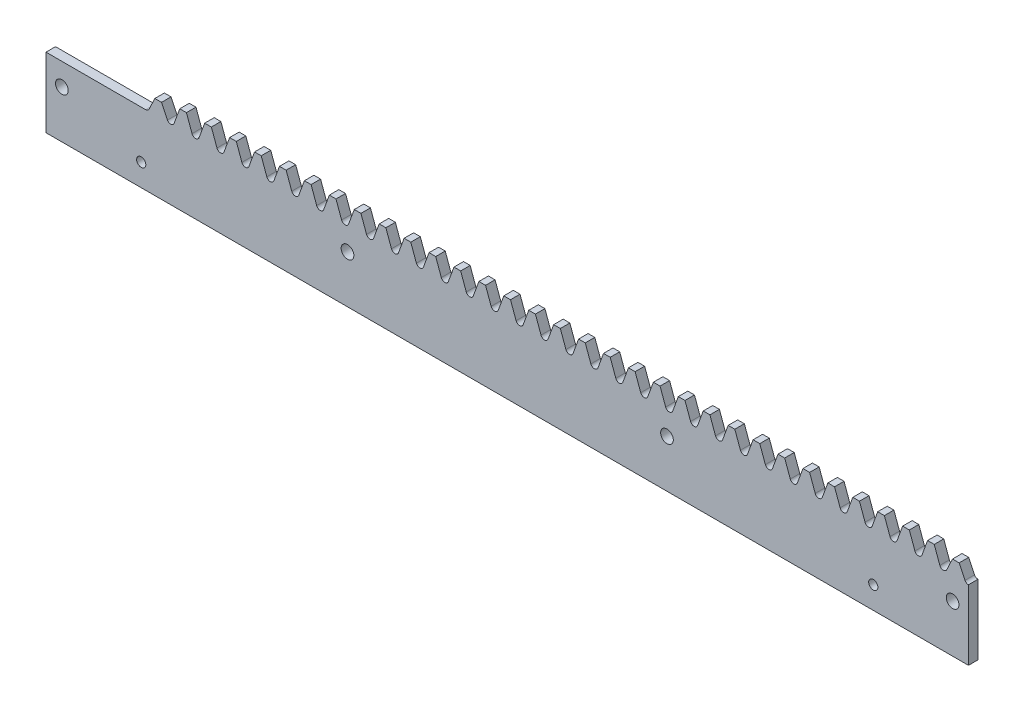
from build123d import *

# Parameters (mm, degrees)
ESQUISSE1_R             = 2
EXTRUSION1_DEPTH        = 3
ESQUISSE4_R             = 1.45
ENL_V_MAT_EXTRU_2_DEPTH = 4


with BuildPart() as part:
    # Esquisse1 → Extrusion1 (new body)
    with BuildSketch(Plane.XY):
        with BuildLine():
            Line((-11.780972452, 22), (19.634954087, 22))
            ThreePointArc((19.634954087, 22), (20.207764851, 22.148388876), (20.636482657, 22.556227657))
            Line((20.636482657, 22.556227657), (22.508375082, 26.5))
            Line((22.508375082, 26.5), (24.615514728, 26.5))
            Line((24.615514728, 26.5), (26.487407153, 22.556227657))
            ThreePointArc((26.487407153, 22.556227657), (26.916124959, 22.148388876), (27.488935722, 22))
            ThreePointArc((27.488935722, 22), (28.165627746, 22.213360175), (28.597563031, 22.776269199))
            Line((28.597563031, 22.776269199), (30.362356717, 27.625))
            Line((30.362356717, 27.625), (32.469496363, 27.625))
            Line((32.469496363, 27.625), (34.234290049, 22.776269199))
            ThreePointArc((34.234290049, 22.776269199), (34.666225334, 22.213360175), (35.342917357, 22))
            ThreePointArc((35.342917357, 22), (36.019609381, 22.213360175), (36.451544666, 22.776269199))
            Line((36.451544666, 22.776269199), (38.216338352, 27.625))
            Line((38.216338352, 27.625), (40.323477998, 27.625))
            Line((40.323477998, 27.625), (42.088271684, 22.776269199))
            ThreePointArc((42.088271684, 22.776269199), (42.520206969, 22.213360175), (43.196898992, 22))
            ThreePointArc((43.196898992, 22), (43.873591016, 22.213360175), (44.305526301, 22.776269199))
            Line((44.305526301, 22.776269199), (46.070319987, 27.625))
            Line((46.070319987, 27.625), (48.177459633, 27.625))
            Line((48.177459633, 27.625), (49.942253319, 22.776269199))
            ThreePointArc((49.942253319, 22.776269199), (50.374188604, 22.213360175), (51.050880627, 22))
            ThreePointArc((51.050880627, 22), (51.727572651, 22.213360175), (52.159507936, 22.776269199))
            Line((52.159507936, 22.776269199), (53.924301622, 27.625))
            Line((53.924301622, 27.625), (56.031441268, 27.625))
            Line((56.031441268, 27.625), (57.796234954, 22.776269199))
            ThreePointArc((57.796234954, 22.776269199), (58.228170239, 22.213360175), (58.904862262, 22))
            ThreePointArc((58.904862262, 22), (59.581554286, 22.213360175), (60.013489571, 22.776269199))
            Line((60.013489571, 22.776269199), (61.778283257, 27.625))
            Line((61.778283257, 27.625), (63.885422903, 27.625))
            Line((63.885422903, 27.625), (65.650216589, 22.776269199))
            ThreePointArc((65.650216589, 22.776269199), (66.082151874, 22.213360175), (66.758843897, 22))
            ThreePointArc((66.758843897, 22), (67.435535921, 22.213360175), (67.867471206, 22.776269199))
            Line((67.867471206, 22.776269199), (69.632264892, 27.625))
            Line((69.632264892, 27.625), (71.739404538, 27.625))
            Line((71.739404538, 27.625), (73.504198224, 22.776269199))
            ThreePointArc((73.504198224, 22.776269199), (73.936133509, 22.213360175), (74.612825532, 22))
            ThreePointArc((74.612825532, 22), (75.289517556, 22.213360175), (75.721452841, 22.776269199))
            Line((75.721452841, 22.776269199), (77.486246527, 27.625))
            Line((77.486246527, 27.625), (79.593386173, 27.625))
            Line((79.593386173, 27.625), (81.358179859, 22.776269199))
            ThreePointArc((81.358179859, 22.776269199), (81.790115144, 22.213360175), (82.466807167, 22))
            ThreePointArc((82.466807167, 22), (83.143499191, 22.213360175), (83.575434476, 22.776269199))
            Line((83.575434476, 22.776269199), (85.340228162, 27.625))
            Line((85.340228162, 27.625), (87.447367808, 27.625))
            Line((87.447367808, 27.625), (89.212161494, 22.776269199))
            ThreePointArc((89.212161494, 22.776269199), (89.644096779, 22.213360175), (90.320788802, 22))
            ThreePointArc((90.320788802, 22), (90.997480826, 22.213360175), (91.429416111, 22.776269199))
            Line((91.429416111, 22.776269199), (93.194209797, 27.625))
            Line((93.194209797, 27.625), (95.301349443, 27.625))
            Line((95.301349443, 27.625), (97.066143129, 22.776269199))
            ThreePointArc((97.066143129, 22.776269199), (97.498078414, 22.213360175), (98.174770437, 22))
            ThreePointArc((98.174770437, 22), (98.851462461, 22.213360175), (99.283397746, 22.776269199))
            Line((99.283397746, 22.776269199), (101.048191432, 27.625))
            Line((101.048191432, 27.625), (103.155331078, 27.625))
            Line((103.155331078, 27.625), (104.920124764, 22.776269199))
            ThreePointArc((104.920124764, 22.776269199), (105.352060049, 22.213360175), (106.028752072, 22))
            ThreePointArc((106.028752072, 22), (106.705444096, 22.213360175), (107.137379381, 22.776269199))
            Line((107.137379381, 22.776269199), (108.902173067, 27.625))
            Line((108.902173067, 27.625), (111.009312713, 27.625))
            Line((111.009312713, 27.625), (112.774106399, 22.776269199))
            ThreePointArc((112.774106399, 22.776269199), (113.206041684, 22.213360175), (113.882733707, 22))
            ThreePointArc((113.882733707, 22), (114.559425731, 22.213360175), (114.991361016, 22.776269199))
            Line((114.991361016, 22.776269199), (116.756154702, 27.625))
            Line((116.756154702, 27.625), (118.863294348, 27.625))
            Line((118.863294348, 27.625), (120.628088034, 22.776269199))
            ThreePointArc((120.628088034, 22.776269199), (121.060023319, 22.213360175), (121.736715342, 22))
            ThreePointArc((121.736715342, 22), (122.413407366, 22.213360175), (122.845342651, 22.776269199))
            Line((122.845342651, 22.776269199), (124.610136337, 27.625))
            Line((124.610136337, 27.625), (126.717275983, 27.625))
            Line((126.717275983, 27.625), (128.482069669, 22.776269199))
            ThreePointArc((128.482069669, 22.776269199), (128.914004954, 22.213360175), (129.590696977, 22))
            ThreePointArc((129.590696977, 22), (130.267389001, 22.213360175), (130.699324286, 22.776269199))
            Line((130.699324286, 22.776269199), (132.464117972, 27.625))
            Line((132.464117972, 27.625), (134.571257618, 27.625))
            Line((134.571257618, 27.625), (136.336051304, 22.776269199))
            ThreePointArc((136.336051304, 22.776269199), (136.767986589, 22.213360175), (137.444678612, 22))
            ThreePointArc((137.444678612, 22), (138.121370636, 22.213360175), (138.553305921, 22.776269199))
            Line((138.553305921, 22.776269199), (140.318099607, 27.625))
            Line((140.318099607, 27.625), (142.425239253, 27.625))
            Line((142.425239253, 27.625), (144.190032939, 22.776269199))
            ThreePointArc((144.190032939, 22.776269199), (144.621968224, 22.213360175), (145.298660247, 22))
            ThreePointArc((145.298660247, 22), (145.975352271, 22.213360175), (146.407287556, 22.776269199))
            Line((146.407287556, 22.776269199), (148.172081242, 27.625))
            Line((148.172081242, 27.625), (150.279220888, 27.625))
            Line((150.279220888, 27.625), (152.044014574, 22.776269199))
            ThreePointArc((152.044014574, 22.776269199), (152.475949859, 22.213360175), (153.152641882, 22))
            ThreePointArc((153.152641882, 22), (153.829333906, 22.213360175), (154.261269191, 22.776269199))
            Line((154.261269191, 22.776269199), (156.026062877, 27.625))
            Line((156.026062877, 27.625), (158.133202523, 27.625))
            Line((158.133202523, 27.625), (159.897996209, 22.776269199))
            ThreePointArc((159.897996209, 22.776269199), (160.329931494, 22.213360175), (161.006623517, 22))
            ThreePointArc((161.006623517, 22), (161.683315541, 22.213360175), (162.115250826, 22.776269199))
            Line((162.115250826, 22.776269199), (163.880044512, 27.625))
            Line((163.880044512, 27.625), (165.987184158, 27.625))
            Line((165.987184158, 27.625), (167.751977844, 22.776269199))
            ThreePointArc((167.751977844, 22.776269199), (168.183913129, 22.213360175), (168.860605152, 22))
            ThreePointArc((168.860605152, 22), (169.537297176, 22.213360175), (169.969232461, 22.776269199))
            Line((169.969232461, 22.776269199), (171.734026147, 27.625))
            Line((171.734026147, 27.625), (173.841165793, 27.625))
            Line((173.841165793, 27.625), (175.605959479, 22.776269199))
            ThreePointArc((175.605959479, 22.776269199), (176.037894764, 22.213360175), (176.714586787, 22))
            ThreePointArc((176.714586787, 22), (177.391278811, 22.213360175), (177.823214096, 22.776269199))
            Line((177.823214096, 22.776269199), (179.588007782, 27.625))
            Line((179.588007782, 27.625), (181.695147428, 27.625))
            Line((181.695147428, 27.625), (183.459941114, 22.776269199))
            ThreePointArc((183.459941114, 22.776269199), (183.891876399, 22.213360175), (184.568568422, 22))
            ThreePointArc((184.568568422, 22), (185.245260446, 22.213360175), (185.677195731, 22.776269199))
            Line((185.677195731, 22.776269199), (187.441989417, 27.625))
            Line((187.441989417, 27.625), (189.549129063, 27.625))
            Line((189.549129063, 27.625), (191.313922749, 22.776269199))
            ThreePointArc((191.313922749, 22.776269199), (191.745858034, 22.213360175), (192.422550057, 22))
            ThreePointArc((192.422550057, 22), (193.099242081, 22.213360175), (193.531177366, 22.776269199))
            Line((193.531177366, 22.776269199), (195.295971052, 27.625))
            Line((195.295971052, 27.625), (197.403110698, 27.625))
            Line((197.403110698, 27.625), (199.167904384, 22.776269199))
            ThreePointArc((199.167904384, 22.776269199), (199.599839669, 22.213360175), (200.276531692, 22))
            ThreePointArc((200.276531692, 22), (200.953223716, 22.213360175), (201.385159001, 22.776269199))
            Line((201.385159001, 22.776269199), (203.149952687, 27.625))
            Line((203.149952687, 27.625), (205.257092333, 27.625))
            Line((205.257092333, 27.625), (207.021886019, 22.776269199))
            ThreePointArc((207.021886019, 22.776269199), (207.453821304, 22.213360175), (208.130513327, 22))
            ThreePointArc((208.130513327, 22), (208.807205351, 22.213360175), (209.239140636, 22.776269199))
            Line((209.239140636, 22.776269199), (211.003934322, 27.625))
            Line((211.003934322, 27.625), (213.111073968, 27.625))
            Line((213.111073968, 27.625), (214.875867654, 22.776269199))
            ThreePointArc((214.875867654, 22.776269199), (215.307802939, 22.213360175), (215.984494962, 22))
            ThreePointArc((215.984494962, 22), (216.661186986, 22.213360175), (217.093122271, 22.776269199))
            Line((217.093122271, 22.776269199), (218.857915957, 27.625))
            Line((218.857915957, 27.625), (220.965055603, 27.625))
            Line((220.965055603, 27.625), (222.729849289, 22.776269199))
            ThreePointArc((222.729849289, 22.776269199), (223.161784574, 22.213360175), (223.838476597, 22))
            ThreePointArc((223.838476597, 22), (224.515168621, 22.213360175), (224.947103906, 22.776269199))
            Line((224.947103906, 22.776269199), (226.711897592, 27.625))
            Line((226.711897592, 27.625), (228.819037238, 27.625))
            Line((228.819037238, 27.625), (230.583830924, 22.776269199))
            ThreePointArc((230.583830924, 22.776269199), (231.015766209, 22.213360175), (231.692458232, 22))
            ThreePointArc((231.692458232, 22), (232.369150256, 22.213360175), (232.801085541, 22.776269199))
            Line((232.801085541, 22.776269199), (234.565879227, 27.625))
            Line((234.565879227, 27.625), (236.673018873, 27.625))
            Line((236.673018873, 27.625), (238.437812559, 22.776269199))
            ThreePointArc((238.437812559, 22.776269199), (238.869747844, 22.213360175), (239.546439867, 22))
            ThreePointArc((239.546439867, 22), (240.223131891, 22.213360175), (240.655067176, 22.776269199))
            Line((240.655067176, 22.776269199), (242.419860862, 27.625))
            Line((242.419860862, 27.625), (244.527000508, 27.625))
            Line((244.527000508, 27.625), (246.291794194, 22.776269199))
            ThreePointArc((246.291794194, 22.776269199), (246.723729479, 22.213360175), (247.400421502, 22))
            ThreePointArc((247.400421502, 22), (248.077113526, 22.213360175), (248.509048811, 22.776269199))
            Line((248.509048811, 22.776269199), (250.273842497, 27.625))
            Line((250.273842497, 27.625), (252.380982143, 27.625))
            Line((252.380982143, 27.625), (254.145775829, 22.776269199))
            ThreePointArc((254.145775829, 22.776269199), (254.577711114, 22.213360175), (255.254403137, 22))
            ThreePointArc((255.254403137, 22), (255.931095161, 22.213360175), (256.363030446, 22.776269199))
            Line((256.363030446, 22.776269199), (258.127824132, 27.625))
            Line((258.127824132, 27.625), (260.234963778, 27.625))
            Line((260.234963778, 27.625), (261.999757464, 22.776269199))
            ThreePointArc((261.999757464, 22.776269199), (262.431692749, 22.213360175), (263.108384772, 22))
            ThreePointArc((263.108384772, 22), (263.785076796, 22.213360175), (264.217012081, 22.776269199))
            Line((264.217012081, 22.776269199), (265.981805767, 27.625))
            Line((265.981805767, 27.625), (268.088945413, 27.625))
            Line((268.088945413, 27.625), (269.853739099, 22.776269199))
            ThreePointArc((269.853739099, 22.776269199), (270.285674384, 22.213360175), (270.962366407, 22))
            ThreePointArc((270.962366407, 22), (271.572652612, 22.17011153), (272.006944946, 22.631389486))
            Line((272.006944946, 22.631389486), (273.835787402, 26.5))
            Line((273.835787402, 26.5), (275.942927048, 26.5))
            Line((275.942927048, 26.5), (277.771769504, 22.631389486))
            ThreePointArc((277.771769504, 22.631389486), (278.231733017, 22.155033667), (278.875867654, 22.001502336))
            Line((278.875867654, 22.001502336), (278.875867654, 0))
            Line((278.875867654, 0), (-11.780972452, 0))
            Line((-11.780972452, 0), (-11.780972452, 22))
        make_face()
        with Locations((183.875867654, 15)):
            Circle(ESQUISSE1_R, mode=Mode.SUBTRACT)
        with Locations((83.219027548, 15)):
            Circle(ESQUISSE1_R, mode=Mode.SUBTRACT)
        with Locations((-6.780972452, 15)):
            Circle(ESQUISSE1_R, mode=Mode.SUBTRACT)
        with Locations((273.875867654, 15)):
            Circle(ESQUISSE1_R, mode=Mode.SUBTRACT)
    extrude(amount=EXTRUSION1_DEPTH)

    # Esquisse4 → Enlèv. mat.-Extru.2 (cut, through all)
    with BuildSketch(Plane.XY.offset(3)):
        with Locations((18.219027547, 7)):
            Circle(ESQUISSE4_R)
        with Locations((248.875867654, 7)):
            Circle(ESQUISSE4_R)
    extrude(amount=-ENL_V_MAT_EXTRU_2_DEPTH, mode=Mode.SUBTRACT)


solid = part.part
